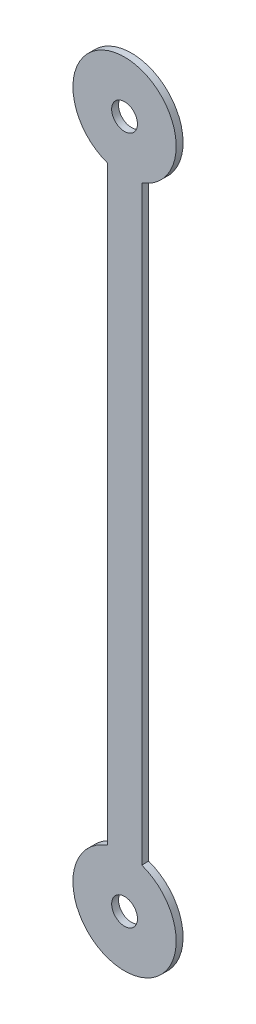
from build123d import *

# Parameters (mm, degrees)
SKETCH1_R           = 0.375
BOSS_EXTRUDE1_DEPTH = 0.1


with BuildPart() as part:
    # Sketch1 → Boss-Extrude1 (new body, symmetric)
    with BuildSketch(Plane.XY):
        with BuildLine():
            Line((-0.5, 8.585786438), (-0.5, -8.585786438))
            ThreePointArc((-0.5, -8.585786438), (0, -11.5), (0.5, -8.585786438))
            Line((0.5, -8.585786438), (0.5, 8.585786438))
            ThreePointArc((0.5, 8.585786438), (0, 11.5), (-0.5, 8.585786438))
        make_face()
        with Locations((0, 10)):
            Circle(SKETCH1_R, mode=Mode.SUBTRACT)
        with Locations((0, -10)):
            Circle(SKETCH1_R, mode=Mode.SUBTRACT)
    extrude(amount=BOSS_EXTRUDE1_DEPTH, both=True)


solid = part.part
